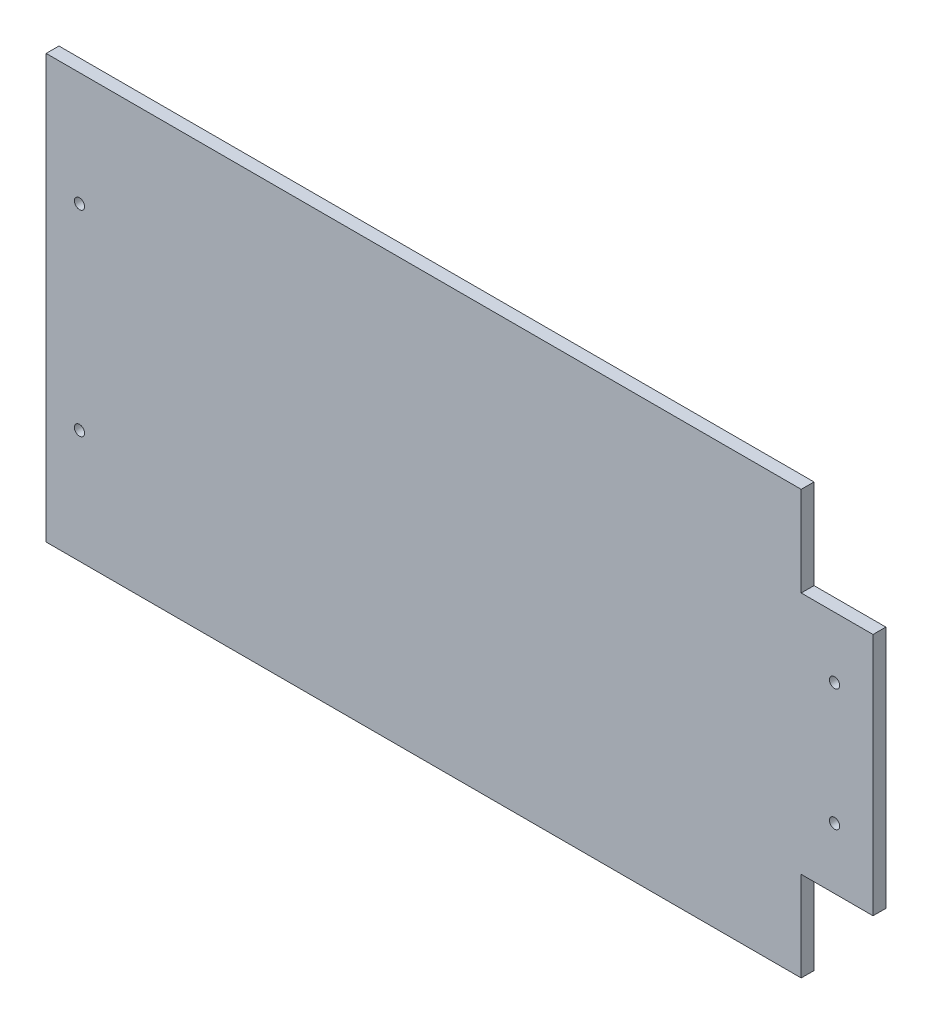
from build123d import *

# Parameters (mm, degrees)
BOSS_EXTRUDE1_DEPTH = 5
SKETCH2_R           = 2
CUT_EXTRUDE1_DEPTH  = 10


with BuildPart() as part:
    # Sketch1 → Boss-Extrude1 (new body)
    with BuildSketch(Plane.XY):
        Polygon((-164.220930233, -82.5), (-164.220930233, 82.5), (130.179069767, 82.5), (130.179069767, 47.5), (158.179069767, 47.5), (158.179069767, -47.5), (130.179069767, -47.5), (130.179069767, -82.5), align=None)
    extrude(amount=BOSS_EXTRUDE1_DEPTH)

    # Sketch2 → Cut-Extrude1 (cut)
    with BuildSketch(Plane.XY.offset(5)):
        with Locations((-151.220930233, 38.25)):
            Circle(SKETCH2_R)
        with Locations((-151.220930233, -38.25)):
            Circle(SKETCH2_R)
        with Locations((143.179069767, 23.75)):
            Circle(SKETCH2_R)
        with Locations((143.179069767, -23.75)):
            Circle(SKETCH2_R)
    extrude(amount=-CUT_EXTRUDE1_DEPTH, mode=Mode.SUBTRACT)


solid = part.part
